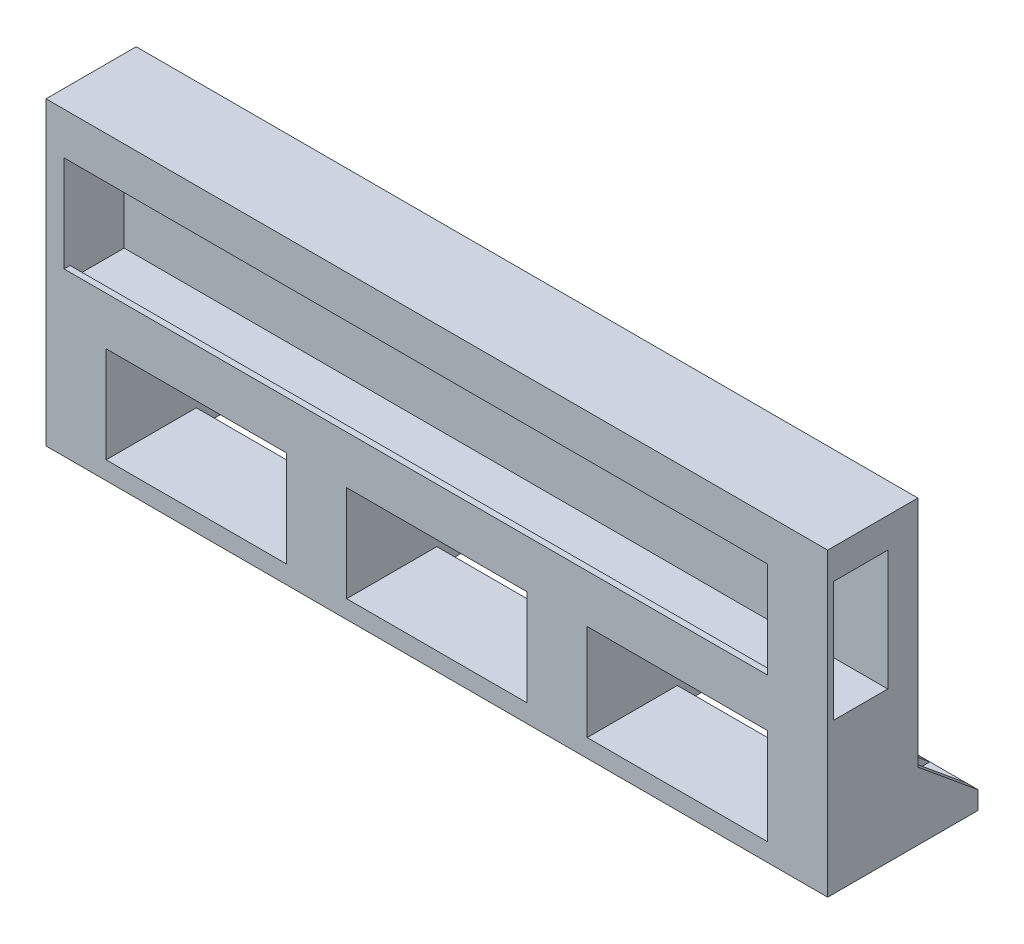
from build123d import *

# Parameters (mm, degrees)
SKETCH1_W               = 130
SKETCH1_H               = 50
BOSS_EXTRUDE1_DEPTH     = 15
CUT_EXTRUDE1_DEPTH      = 1
CUT_EXTRUDE1_DEPTH_BACK = 127
SKETCH4_W               = 10
SKETCH4_H               = 3
BOSS_EXTRUDE2_DEPTH     = 10
SKETCH6_W               = 30
SKETCH6_H               = 16
CUT_EXTRUDE2_DEPTH      = 16
SKETCH7_R               = 1.375
CUT_EXTRUDE3_DEPTH      = 4
SKETCH9_W               = 10
SKETCH9_H               = 3
BOSS_EXTRUDE4_DEPTH     = 10
SKETCH10_R              = 1.375
CUT_EXTRUDE4_DEPTH      = 10
SKETCH11_W              = 10
SKETCH11_H              = 1
BOSS_EXTRUDE5_DEPTH     = 20
SKETCH13_W              = 10
SKETCH13_H              = 3
CUT_EXTRUDE5_DEPTH      = 10
SKETCH14_W              = 10
SKETCH14_H              = 3
CUT_EXTRUDE6_DEPTH      = 10
SKETCH15_W              = 10
SKETCH15_H              = 3
CUT_EXTRUDE7_DEPTH      = 10
SKETCH16_W              = 10
SKETCH16_H              = 3
BOSS_EXTRUDE6_DEPTH     = 10
BOSS_EXTRUDE8_DEPTH     = 10
BOSS_EXTRUDE9_DEPTH     = 10
BOSS_EXTRUDE10_DEPTH    = 10
BOSS_EXTRUDE11_DEPTH    = 10
SKETCH29_W              = 6
SKETCH29_H              = 10
CUT_EXTRUDE10_DEPTH     = 10
SKETCH30_W              = 6
SKETCH30_H              = 10
CUT_EXTRUDE11_DEPTH     = 10
SKETCH31_W              = 6
SKETCH31_H              = 10
CUT_EXTRUDE12_DEPTH     = 10
SKETCH32_W              = 6
SKETCH32_H              = 10
CUT_EXTRUDE13_DEPTH     = 10
SKETCH35_R              = 1.4
CUT_EXTRUDE14_DEPTH     = 5


with BuildPart() as part:
    # Sketch1 → Boss-Extrude1 (new body)
    with BuildSketch(Plane.XY):
        with Locations((-150.849056604, 105)):
            Rectangle(SKETCH1_W, SKETCH1_H)
    extrude(amount=BOSS_EXTRUDE1_DEPTH)

    # Sketch3 → Cut-Extrude1 (cut, two sides)
    with BuildSketch(Plane(origin=(-85.849056604, 0, 0), x_dir=(0, 0, -1), z_dir=(1, 0, 0))) as cut_extrude1_sk:
        Polygon((-14, 125), (-5, 125), (-5, 105), (-14, 105), (-14, 107), (-15, 107), (-15, 123), (-14, 123), align=None)
    extrude(amount=CUT_EXTRUDE1_DEPTH, mode=Mode.SUBTRACT)
    extrude(cut_extrude1_sk.sketch, amount=-CUT_EXTRUDE1_DEPTH_BACK, mode=Mode.SUBTRACT)

    # Sketch4 → Boss-Extrude2 (add)
    with BuildSketch(Plane(origin=(0, 0, 0), x_dir=(-1, 0, 0), z_dir=(0, 0, -1))):
        with Locations((105.849056604, 81.5)):
            Rectangle(SKETCH4_W, SKETCH4_H)
        with Locations((195.849056604, 81.5)):
            Rectangle(SKETCH4_W, SKETCH4_H)
    extrude(amount=BOSS_EXTRUDE2_DEPTH)

    # Sketch6 → Cut-Extrude2 (cut, through all)
    with BuildSketch(Plane(origin=(0, 0, 0), x_dir=(-1, 0, 0), z_dir=(0, 0, -1))):
        with Locations((190.849056604, 91)):
            Rectangle(SKETCH6_W, SKETCH6_H)
        with Locations((150.849056604, 91)):
            Rectangle(SKETCH6_W, SKETCH6_H)
        with Locations((110.849056604, 91)):
            Rectangle(SKETCH6_W, SKETCH6_H)
    extrude(amount=-CUT_EXTRUDE2_DEPTH, mode=Mode.SUBTRACT)

    # Sketch7 → Cut-Extrude3 (cut, through all)
    with BuildSketch(Plane(origin=(0, 83, 0), x_dir=(1, 0, 0), z_dir=(0, 1, 0))):
        with Locations((-105.849056604, 5)):
            Circle(SKETCH7_R)
    cut_extrude3 = extrude(amount=-CUT_EXTRUDE3_DEPTH, mode=Mode.SUBTRACT)

    # Mirror1: Cut-Extrude3 across plane
    add(cut_extrude3.mirror(Plane(origin=(-151, 0, 0), x_dir=(0, 0, 1), z_dir=(1, 0, 0))), mode=Mode.SUBTRACT)

    # Sketch9 → Boss-Extrude4 (add)
    with BuildSketch(Plane(origin=(0, 0, 0), x_dir=(-1, 0, 0), z_dir=(0, 0, -1))):
        with Locations((150.849056604, 81.5)):
            Rectangle(SKETCH9_W, SKETCH9_H)
    extrude(amount=BOSS_EXTRUDE4_DEPTH)

    # Sketch10 → Cut-Extrude4 (cut)
    with BuildSketch(Plane(origin=(0, 83, 0), x_dir=(1, 0, 0), z_dir=(0, 1, 0))):
        with Locations((-150.849056604, 5)):
            Circle(SKETCH10_R)
    extrude(amount=-CUT_EXTRUDE4_DEPTH, mode=Mode.SUBTRACT)

    # Sketch11 → Boss-Extrude5 (add)
    with BuildSketch(Plane(origin=(0, 107, 0), x_dir=(1, 0, 0), z_dir=(0, 1, 0))):
        with Locations((-90.849056604, -14.5)):
            Rectangle(SKETCH11_W, SKETCH11_H)
    extrude(amount=BOSS_EXTRUDE5_DEPTH)

    # Sketch13 → Cut-Extrude5 (cut)
    with BuildSketch(Plane(origin=(0, 0, -10), x_dir=(-1, 0, 0), z_dir=(0, 0, -1))):
        with Locations((105.849056604, 81.5)):
            Rectangle(SKETCH13_W, SKETCH13_H)
    extrude(amount=-CUT_EXTRUDE5_DEPTH, mode=Mode.SUBTRACT)

    # Sketch14 → Cut-Extrude6 (cut)
    with BuildSketch(Plane(origin=(0, 0, -10), x_dir=(-1, 0, 0), z_dir=(0, 0, -1))):
        with Locations((150.849056604, 81.5)):
            Rectangle(SKETCH14_W, SKETCH14_H)
    extrude(amount=-CUT_EXTRUDE6_DEPTH, mode=Mode.SUBTRACT)

    # Sketch15 → Cut-Extrude7 (cut)
    with BuildSketch(Plane(origin=(0, 0, -10), x_dir=(-1, 0, 0), z_dir=(0, 0, -1))):
        with Locations((195.849056604, 81.5)):
            Rectangle(SKETCH15_W, SKETCH15_H)
    extrude(amount=-CUT_EXTRUDE7_DEPTH, mode=Mode.SUBTRACT)

    # Sketch16 → Boss-Extrude6 (add)
    with BuildSketch(Plane(origin=(0, 0, 0), x_dir=(-1, 0, 0), z_dir=(0, 0, -1))):
        with Locations((90.849056604, 81.5)):
            Rectangle(SKETCH16_W, SKETCH16_H)
        with Locations((130.849056604, 81.5)):
            Rectangle(SKETCH16_W, SKETCH16_H)
        with Locations((170.849056604, 81.5)):
            Rectangle(SKETCH16_W, SKETCH16_H)
        with Locations((210.849056604, 81.5)):
            Rectangle(SKETCH16_W, SKETCH16_H)
    extrude(amount=BOSS_EXTRUDE6_DEPTH)

    # Sketch18 → Boss-Extrude8 (add)
    with BuildSketch(Plane(origin=(-85.849056604, 0, 0), x_dir=(0, 0, -1), z_dir=(1, 0, 0))):
        Polygon((10, 83), (0, 91.236285037), (0, 83), align=None)
    extrude(amount=-BOSS_EXTRUDE8_DEPTH)

    # Sketch20 → Boss-Extrude9 (add)
    with BuildSketch(Plane(origin=(-125.849056604, 0, 0), x_dir=(0, 0, -1), z_dir=(1, 0, 0))):
        Polygon((0, 83), (0, 91), (10, 83), align=None)
    extrude(amount=-BOSS_EXTRUDE9_DEPTH)

    # Sketch21 → Boss-Extrude10 (add)
    with BuildSketch(Plane(origin=(-165.849056604, 0, 0), x_dir=(0, 0, -1), z_dir=(1, 0, 0))):
        Polygon((0, 83), (0, 91), (10, 83), align=None)
    extrude(amount=-BOSS_EXTRUDE10_DEPTH)

    # Sketch22 → Boss-Extrude11 (add)
    with BuildSketch(Plane(origin=(-205.849056604, 0, 0), x_dir=(0, 0, -1), z_dir=(1, 0, 0))):
        Polygon((0, 83), (0, 91), (10, 83), align=None)
    extrude(amount=-BOSS_EXTRUDE11_DEPTH)

    # Sketch29 → Cut-Extrude10 (cut)
    with BuildSketch(Plane(origin=(0, 0, -10), x_dir=(-1, 0, 0), z_dir=(0, 0, -1))):
        with Locations((90.849056604, 88)):
            Rectangle(SKETCH29_W, SKETCH29_H)
    extrude(amount=-CUT_EXTRUDE10_DEPTH, mode=Mode.SUBTRACT)

    # Sketch30 → Cut-Extrude11 (cut)
    with BuildSketch(Plane(origin=(0, 0, -10), x_dir=(-1, 0, 0), z_dir=(0, 0, -1))):
        with Locations((130.849056604, 88)):
            Rectangle(SKETCH30_W, SKETCH30_H)
    extrude(amount=-CUT_EXTRUDE11_DEPTH, mode=Mode.SUBTRACT)

    # Sketch31 → Cut-Extrude12 (cut)
    with BuildSketch(Plane(origin=(0, 0, -10), x_dir=(-1, 0, 0), z_dir=(0, 0, -1))):
        with Locations((170.849056604, 88)):
            Rectangle(SKETCH31_W, SKETCH31_H)
    extrude(amount=-CUT_EXTRUDE12_DEPTH, mode=Mode.SUBTRACT)

    # Sketch32 → Cut-Extrude13 (cut)
    with BuildSketch(Plane(origin=(0, 0, -10), x_dir=(-1, 0, 0), z_dir=(0, 0, -1))):
        with Locations((210.849056604, 88)):
            Rectangle(SKETCH32_W, SKETCH32_H)
    extrude(amount=-CUT_EXTRUDE13_DEPTH, mode=Mode.SUBTRACT)

    # Sketch35 → Cut-Extrude14 (cut)
    with BuildSketch(Plane(origin=(0, 83, 0), x_dir=(1, 0, 0), z_dir=(0, 1, 0))):
        with Locations((-210.849056604, 5)):
            Circle(SKETCH35_R)
        with Locations((-170.849056604, 5)):
            Circle(SKETCH35_R)
        with Locations((-130.849056604, 5)):
            Circle(SKETCH35_R)
        with Locations((-90.849056604, 5)):
            Circle(SKETCH35_R)
    extrude(amount=-CUT_EXTRUDE14_DEPTH, mode=Mode.SUBTRACT)


solid = part.part
